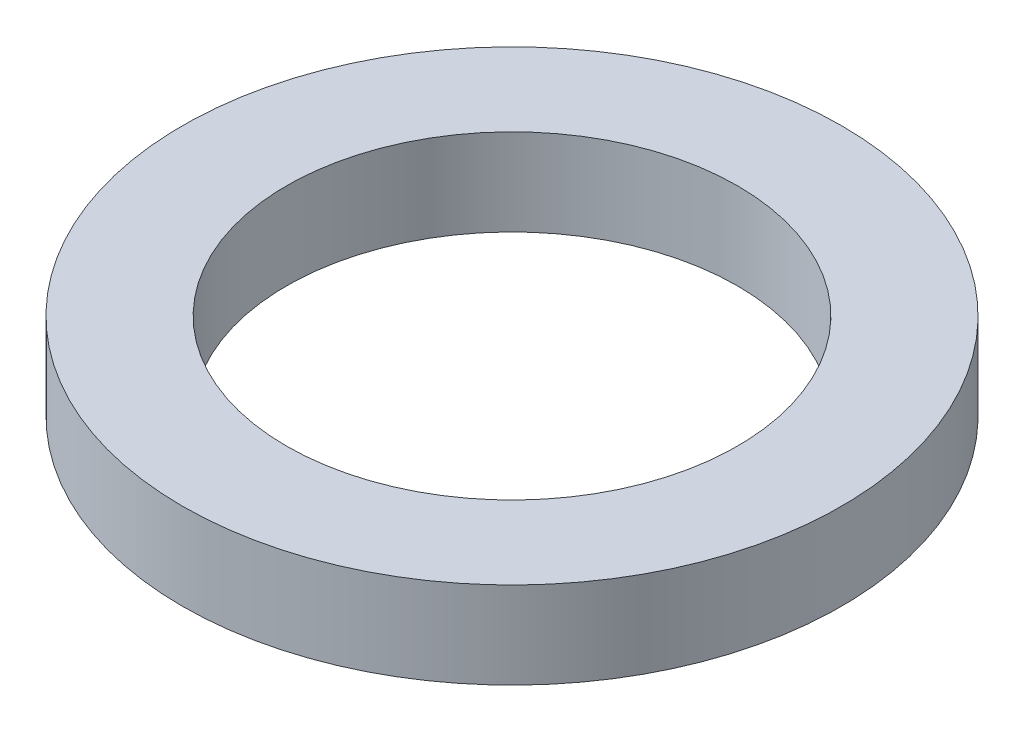
from build123d import *

# Parameters (mm, degrees)
SKETCH_1_R      = 3.8
SKETCH_1_R_2    = 2.6
EXTRUDE_1_DEPTH = 1


with BuildPart() as part:
    # Эскиз1 → Бобышка-Вытянуть1 (new body)
    with BuildSketch(Plane(origin=(0, 0, 0), x_dir=(1, 0, 0), z_dir=(0, 1, 0))):
        Circle(SKETCH_1_R)
        Circle(SKETCH_1_R_2, mode=Mode.SUBTRACT)
    extrude(amount=EXTRUDE_1_DEPTH)


solid = part.part
